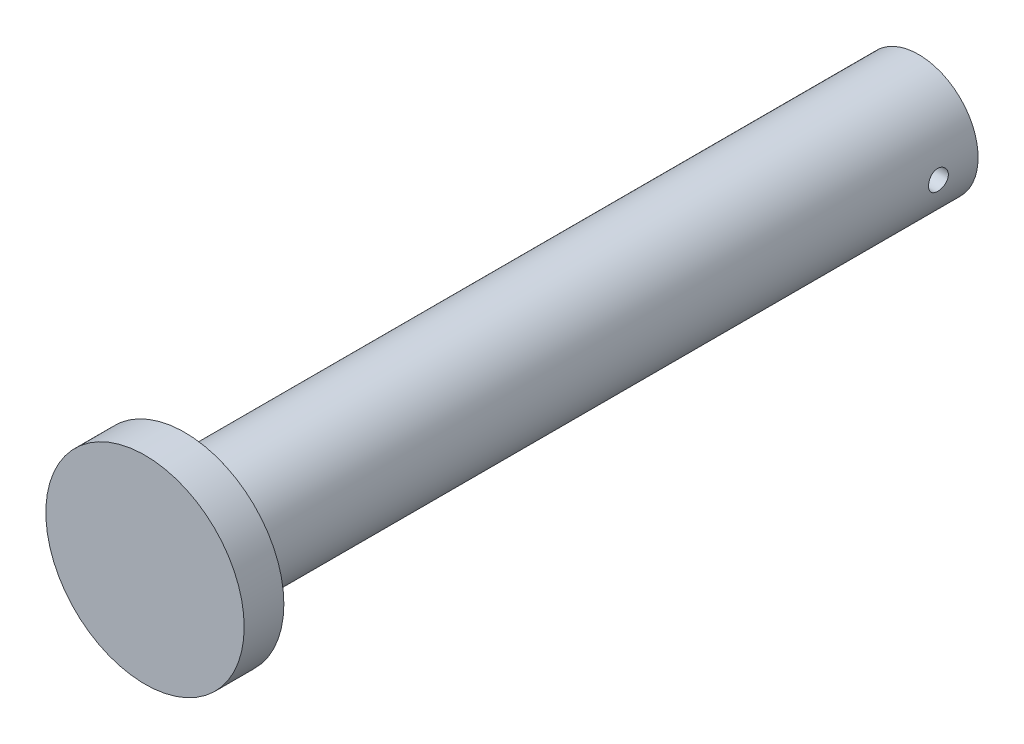
from build123d import *

# Parameters (mm, degrees)
SKETCH1_R           = 25
BOSS_EXTRUDE1_DEPTH = 10
SKETCH5_R           = 15
BOSS_EXTRUDE3_DEPTH = 185
SKETCH6_R           = 2.5
CUT_EXTRUDE1_DEPTH  = 92.5


with BuildPart() as part:
    # Sketch1 → Boss-Extrude1 (new body)
    with BuildSketch(Plane.XY):
        Circle(SKETCH1_R)
    extrude(amount=BOSS_EXTRUDE1_DEPTH)

    # Sketch5 → Boss-Extrude3 (add)
    with BuildSketch(Plane(origin=(0, 0, 0), x_dir=(-1, 0, 0), z_dir=(0, 0, -1))):
        Circle(SKETCH5_R)
    extrude(amount=BOSS_EXTRUDE3_DEPTH)

    # Sketch6 → Cut-Extrude1 (cut, symmetric)
    with BuildSketch(Plane(origin=(0, 0, 0), x_dir=(0, 0, -1), z_dir=(1, 0, 0))):
        with Locations((175, 0)):
            Circle(SKETCH6_R)
    extrude(amount=CUT_EXTRUDE1_DEPTH, both=True, mode=Mode.SUBTRACT)


solid = part.part
